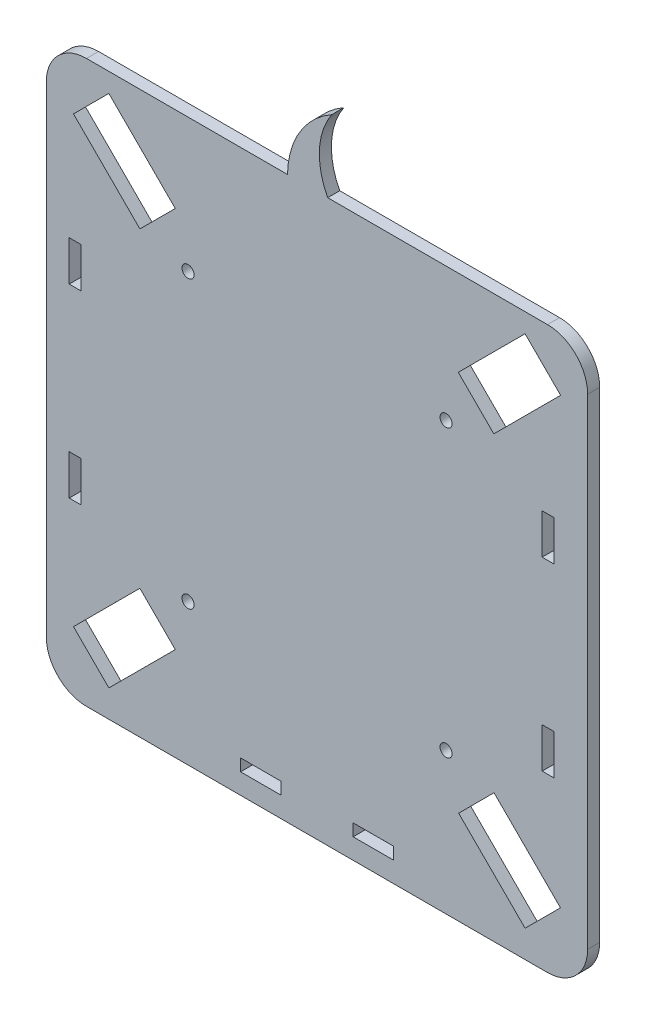
from build123d import *

# Parameters (mm, degrees)
MODEL_R                 = 1.5
MODEL_W                 = 10
MODEL_H                 = 3
MODEL_W_2               = 3
MODEL_H_2               = 10
SALIENTE_EXTRUIR1_DEPTH = 3


with BuildPart() as part:
    # Model → Saliente-Extruir1 (new body)
    with BuildSketch(Plane.XY):
        with BuildLine():
            Line((-32.374234998, -40.258280816), (-32.374234998, 79.347619184))
            ThreePointArc((-32.374234998, 79.347619184), (-29.44530281, 86.418686996), (-22.374234998, 89.347619184))
            Line((-22.374234998, 89.347619184), (27.629122048, 89.347619184))
            ThreePointArc((27.629122048, 89.347619184), (30.675210948, 100.014701803), (38.63501695, 107.741719184))
            ThreePointArc((38.63501695, 107.741719184), (35.575059813, 98.684501141), (37.629122048, 89.347619184))
            Line((37.629122048, 89.347619184), (92.301279094, 89.347619184))
            ThreePointArc((92.301279094, 89.347619184), (99.372346906, 86.418686996), (102.301279094, 79.347619184))
            Line((102.301279094, 79.347619184), (102.301279094, -40.258280816))
            ThreePointArc((102.301279094, -40.258280816), (99.372346906, -47.329348628), (92.301279094, -50.258280816))
            Line((92.301279094, -50.258280816), (-22.374234998, -50.258280816))
            ThreePointArc((-22.374234998, -50.258280816), (-29.44530281, -47.329348628), (-32.374234998, -40.258280816))
        make_face()
        with Locations((67.080084989, -14.999118146)):
            Circle(MODEL_R, mode=Mode.SUBTRACT)
        with Locations((2.884992575, -15.037151741)):
            Circle(MODEL_R, mode=Mode.SUBTRACT)
        with Locations((2.884992575, 56.088341611)):
            Circle(MODEL_R, mode=Mode.SUBTRACT)
        with Locations((67.080084989, 56.088341611)):
            Circle(MODEL_R, mode=Mode.SUBTRACT)
        Polygon((43.960184493, -45.18534075), (43.960184493, -42.18534075), (53.960179079, -42.17493485), (53.960179079, -45.18534075), align=None, mode=Mode.SUBTRACT)
        with Locations((20.960165002, -43.68534075)):
            Rectangle(MODEL_W, MODEL_H, mode=Mode.SUBTRACT)
        Polygon((-0.287033943, 68.061018129), (-9.087685043, 59.260369229), (-25.611384998, 75.784069184), (-16.810734998, 84.584719184), align=None, mode=Mode.SUBTRACT)
        Polygon((78.959502691, 59.128875015), (95.576512855, 75.745885675), (86.737677959, 84.584720308), (70.120668893, 67.967710748), align=None, mode=Mode.SUBTRACT)
        Polygon((-25.611384913, -34.694730812), (-16.810686053, -43.495431871), (-0.28698502, -26.971730838), (-9.087686285, -18.171028474), align=None, mode=Mode.SUBTRACT)
        Polygon((86.737728061, -43.495431849), (95.538379094, -34.694780816), (79.014679094, -18.171080816), (70.214029117, -26.971730793), align=None, mode=Mode.SUBTRACT)
        with Locations((92.48239949, 43.571870396)):
            Rectangle(MODEL_W_2, MODEL_H_2, mode=Mode.SUBTRACT)
        with Locations((92.48239949, -2.520680527)):
            Rectangle(MODEL_W_2, MODEL_H_2, mode=Mode.SUBTRACT)
        with Locations((-25.18093295, -2.520680527)):
            Rectangle(MODEL_W_2, MODEL_H_2, mode=Mode.SUBTRACT)
        with Locations((-25.18093295, 43.571870396)):
            Rectangle(MODEL_W_2, MODEL_H_2, mode=Mode.SUBTRACT)
    extrude(amount=SALIENTE_EXTRUIR1_DEPTH)


solid = part.part
